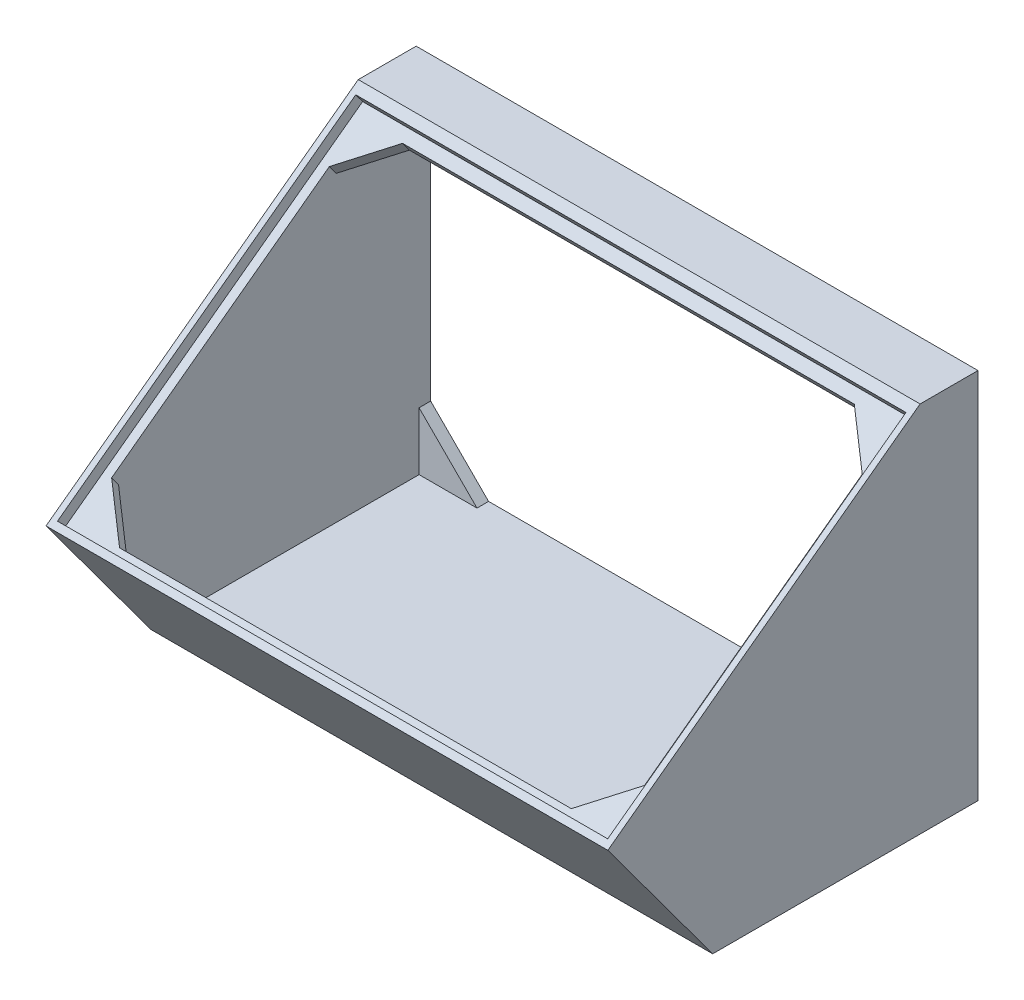
from build123d import *

# Parameters (mm, degrees)
BOSS_EXTRUDE1_DEPTH = 97
SHELL1_T            = -2.5
SKETCH2_W           = 95
SKETCH2_H           = 64
CUT_EXTRUDE1_DEPTH  = 2
BOSS_EXTRUDE2_DEPTH = 93
BOSS_EXTRUDE3_DEPTH = 2
BOSS_EXTRUDE4_DEPTH = 2


with BuildPart() as part:
    # Sketch1 → Boss-Extrude1 (new body)
    with BuildSketch(Plane(origin=(0, 0, 0), x_dir=(0, 0, -1), z_dir=(1, 0, 0))):
        Polygon((0, 41.416666667), (-10, 41.416666667), (-63.911408917, 1.635264119), (-45.805595857, -22.901575437), (0, -22.901575437), align=None)
    extrude(amount=BOSS_EXTRUDE1_DEPTH)

    # Shell1
    shell1_openings = [part.faces().sort_by_distance(p)[0] for p in [
        (48.5, 9.257545615, 0),
        (48.5, 21.525965393, 36.955704458),
    ]]
    offset(amount=SHELL1_T, openings=shell1_openings, kind=Kind.INTERSECTION)

    # Sketch2 → Cut-Extrude1 (cut)
    with BuildSketch(Plane(origin=(0, 31.593177041, 23.312707252), x_dir=(1, 0, 0), z_dir=(0, 0.804647894, 0.593752277))):
        with Locations((48.500142071, -17.236366389)):
            Rectangle(SKETCH2_W, SKETCH2_H)
    extrude(amount=-CUT_EXTRUDE1_DEPTH, mode=Mode.SUBTRACT)

    # Sketch3 → Boss-Extrude2 (add)
    with BuildSketch(Plane.ZY.offset(-94.5)):
        Polygon((11.85497179, 37.56231777), (10.245676001, 38.749822323), (10.36879098, 38.916666667), (6.65116187, 38.916666667), (10.667467236, 35.953021981), align=None)
    extrude(amount=BOSS_EXTRUDE2_DEPTH)

    # Sketch4 → Boss-Extrude3 (add)
    with BuildSketch(Plane(origin=(0, 0, 0), x_dir=(-1, 0, 0), z_dir=(0, 0, -1))):
        Polygon((-94.5, -10.401575437), (-84.5, -20.401575437), (-94.5, -20.401575437), align=None)
        Polygon((-84.5, 38.916666667), (-94.5, 28.916666667), (-94.5, 38.916666667), align=None)
        Polygon((-2.5, 38.916666667), (-2.5, 28.916666667), (-12.5, 38.916666667), align=None)
        Polygon((-2.5, -20.401575437), (-2.5, -10.401575437), (-12.5, -20.401575437), align=None)
    extrude(amount=-BOSS_EXTRUDE3_DEPTH)

    # Sketch5 → Boss-Extrude4 (add)
    with BuildSketch(Plane(origin=(0, 29.983881253, 22.125202698), x_dir=(1, 0, 0), z_dir=(0, 0.804647894, 0.593752277))):
        Polygon((2.5, 12.763633611), (2.5, 5.763633611), (9.5, 12.763633611), align=None)
        Polygon((2.5, -47.955238811), (9.5, -47.955238811), (2.5, -40.955238811), align=None)
        Polygon((94.5, -47.955238811), (94.5, -40.955238811), (87.5, -47.955238811), align=None)
        Polygon((94.5, 12.763633611), (94.5, 5.763633611), (87.5, 12.763633611), align=None)
    extrude(amount=-BOSS_EXTRUDE4_DEPTH)


solid = part.part
